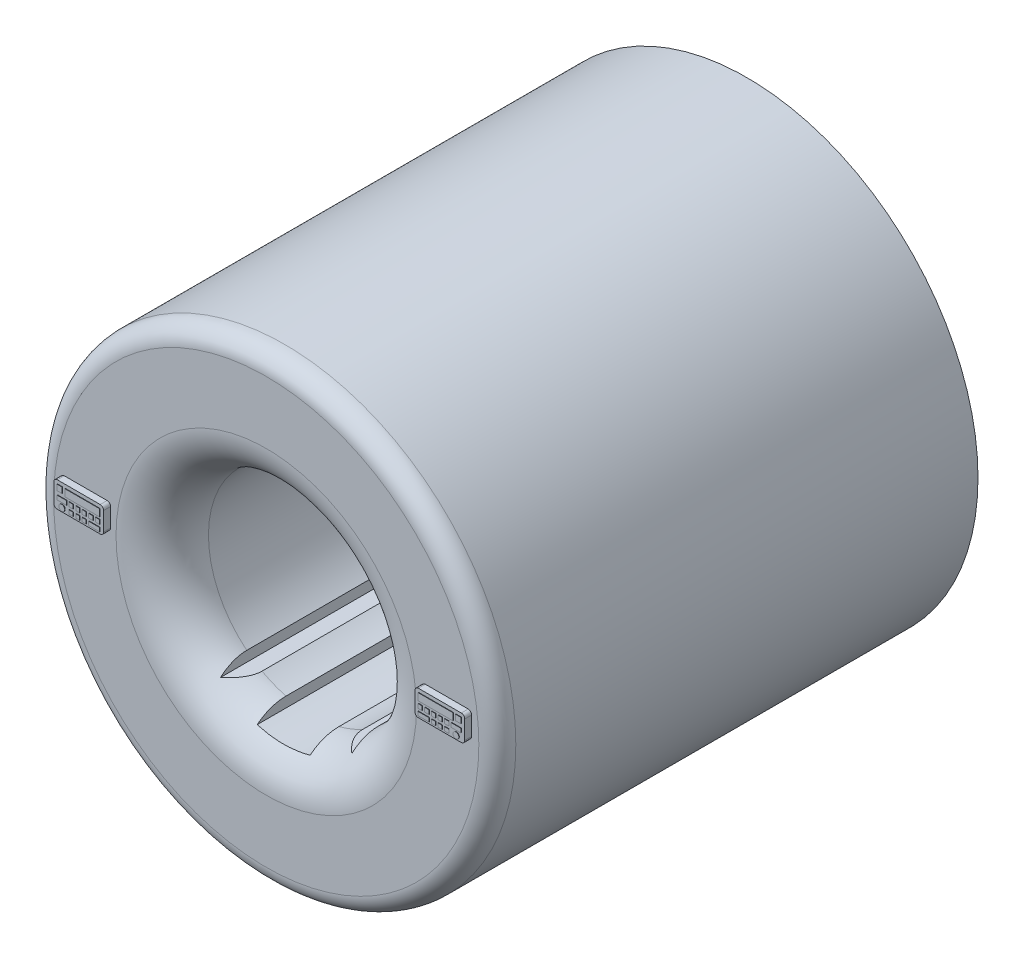
from build123d import *

# Parameters (mm, degrees)
SKETCH1_R           = 100
SKETCH1_R_2         = 45
BOSS_EXTRUDE1_DEPTH = 200
FILLET1_R           = 8
FILLET2_R           = 20
CUT_EXTRUDE1_DEPTH  = 200
SKETCH3_W           = 21.544123994
SKETCH3_H           = 11.057339859
BOSS_EXTRUDE2_DEPTH = 3
FILLET3_R           = 1.5
SKETCH4_R           = 1.289060933
SKETCH4_W           = 15.13149362
SKETCH4_H           = 3.065252971
SKETCH4_W_2         = 2.299952362
SKETCH4_H_2         = 2.429436964
SKETCH4_W_3         = 1.819095979
SKETCH4_H_3         = 1.788232519
SKETCH4_W_4         = 1.827971019
SKETCH4_W_5         = 1.693323788
SKETCH4_W_6         = 1.708755518
SKETCH4_W_7         = 1.86770952
SKETCH4_W_8         = 4.247138883
SKETCH4_W_9         = 4.75974501
SKETCH4_H_4         = 1.629278517
BOSS_EXTRUDE3_DEPTH = 0.2
SKETCH5_R           = 100
BOSS_EXTRUDE4_DEPTH = 8
SCALE1_SCALE        = 15.6
SCALE2_SCALE        = 0.5


with BuildPart() as part:
    # Sketch1 → Boss-Extrude1 (new body)
    with BuildSketch(Plane.XY):
        Circle(SKETCH1_R)
        Circle(SKETCH1_R_2, mode=Mode.SUBTRACT)
    extrude(amount=BOSS_EXTRUDE1_DEPTH)

    # Fillet1
    fillet1_edges = [part.edges().sort_by_distance(p)[0] for p in [
        (-100, 0, 200),
    ]]
    fillet(fillet1_edges, radius=FILLET1_R)

    # Fillet2
    fillet2_edges = [part.edges().sort_by_distance(p)[0] for p in [
        (-45, 0, 200),
    ]]
    fillet(fillet2_edges, radius=FILLET2_R)

    # Sketch2 → Cut-Extrude1 (cut)
    with BuildSketch(Plane(origin=(0, 0, 0), x_dir=(-1, 0, 0), z_dir=(0, 0, -1))):
        with BuildLine():
            Line((-28.43159427, -34.880430721), (28.43159427, -34.880430721))
            Line((28.43159427, -34.880430721), (28.43159427, -39.361060603))
            Line((28.43159427, -39.361060603), (11.44568617, -39.361060603))
            Line((11.44568617, -39.361060603), (11.44568617, -48.0006973))
            ThreePointArc((11.44568617, -48.0006973), (0, -49.480629882), (-11.44568617, -48.0006973))
            Line((-11.44568617, -48.0006973), (-11.44568617, -39.361060603))
            Line((-11.44568617, -39.361060603), (-28.43159427, -39.361060603))
            Line((-28.43159427, -39.361060603), (-28.43159427, -34.880430721))
        make_face()
    extrude(amount=-CUT_EXTRUDE1_DEPTH, mode=Mode.SUBTRACT)

    # Sketch3 → Boss-Extrude2 (add)
    with BuildSketch(Plane.XY.offset(200)):
        with Locations((78.121999913, 5.52866993)):
            Rectangle(SKETCH3_W, SKETCH3_H)
        with Locations((-78.121999913, 5.52866993)):
            Rectangle(SKETCH3_W, SKETCH3_H)
    extrude(amount=BOSS_EXTRUDE2_DEPTH)

    # Fillet3
    fillet3_edges = [part.edges().sort_by_distance(p)[0] for p in [
        (67.349937916, 11.057339859, 201.5),
        (67.349937916, 0, 201.5),
        (88.89406191, 0, 201.5),
        (88.89406191, 11.057339859, 201.5),
        (-88.89406191, 0, 201.5),
        (-67.349937916, 0, 201.5),
        (-67.349937916, 11.057339859, 201.5),
        (-88.89406191, 11.057339859, 201.5),
    ]]
    fillet(fillet3_edges, radius=FILLET3_R)

    # Sketch4 → Boss-Extrude3 (add)
    with BuildSketch(Plane.XY.offset(203)):
        with Locations((85.270492468, 1.703597588)):
            Circle(SKETCH4_R)
        with Locations((-85.270492468, 1.703597588)):
            Circle(SKETCH4_R)
        with Locations((76.415684726, 8.024713374)):
            Rectangle(SKETCH4_W, SKETCH4_H)
        with Locations((86.244085729, 8.342621377)):
            Rectangle(SKETCH4_W_2, SKETCH4_H_2)
        with Locations((69.759485906, 4.564769617)):
            Rectangle(SKETCH4_W_3, SKETCH4_H_3)
        with Locations((72.695697416, 4.564769617)):
            Rectangle(SKETCH4_W_4, SKETCH4_H_3)
        with Locations((75.569022832, 4.564769617)):
            Rectangle(SKETCH4_W_5, SKETCH4_H_3)
        with Locations((78.358433726, 4.564769617)):
            Rectangle(SKETCH4_W_6, SKETCH4_H_3)
        with Locations((81.259344257, 4.564769617)):
            Rectangle(SKETCH4_W_7, SKETCH4_H_3)
        with Locations((85.270492469, 4.564769617)):
            Rectangle(SKETCH4_W_8, SKETCH4_H_3)
        with Locations((71.229810421, 1.703597588)):
            Rectangle(SKETCH4_W_9, SKETCH4_H_4)
        with Locations((75.569022832, 1.703597588)):
            Rectangle(SKETCH4_W_5, SKETCH4_H_4)
        with Locations((78.358433726, 1.703597588)):
            Rectangle(SKETCH4_W_6, SKETCH4_H_4)
        with Locations((81.259344257, 1.703597588)):
            Rectangle(SKETCH4_W_7, SKETCH4_H_4)
        with Locations((-81.259344257, 1.703597588)):
            Rectangle(SKETCH4_W_7, SKETCH4_H_4)
        with Locations((-78.358433726, 1.703597588)):
            Rectangle(SKETCH4_W_6, SKETCH4_H_4)
        with Locations((-75.569022832, 1.703597588)):
            Rectangle(SKETCH4_W_5, SKETCH4_H_4)
        with Locations((-71.229810421, 1.703597588)):
            Rectangle(SKETCH4_W_9, SKETCH4_H_4)
        with Locations((-85.270492469, 4.564769617)):
            Rectangle(SKETCH4_W_8, SKETCH4_H_3)
        with Locations((-81.259344257, 4.564769617)):
            Rectangle(SKETCH4_W_7, SKETCH4_H_3)
        with Locations((-78.358433726, 4.564769617)):
            Rectangle(SKETCH4_W_6, SKETCH4_H_3)
        with Locations((-75.569022832, 4.564769617)):
            Rectangle(SKETCH4_W_5, SKETCH4_H_3)
        with Locations((-72.695697416, 4.564769617)):
            Rectangle(SKETCH4_W_4, SKETCH4_H_3)
        with Locations((-69.759485906, 4.564769617)):
            Rectangle(SKETCH4_W_3, SKETCH4_H_3)
        with Locations((-86.244085729, 8.342621377)):
            Rectangle(SKETCH4_W_2, SKETCH4_H_2)
        with Locations((-76.415684726, 8.024713374)):
            Rectangle(SKETCH4_W, SKETCH4_H)
    extrude(amount=BOSS_EXTRUDE3_DEPTH)

    # Sketch5 → Boss-Extrude4 (add)
    with BuildSketch(Plane(origin=(0, 0, 0), x_dir=(-1, 0, 0), z_dir=(0, 0, -1))):
        Circle(SKETCH5_R)
        with BuildLine():
            Line((-28.43159427, -39.361060603), (-28.43159427, -34.880430721))
            ThreePointArc((-28.43159427, -34.880430721), (0, 45), (28.43159427, -34.880430721))
            Line((28.43159427, -34.880430721), (28.43159427, -39.361060603))
            Line((28.43159427, -39.361060603), (21.810706275, -39.361060603))
            ThreePointArc((21.810706275, -39.361060603), (16.757721923, -41.763366195), (11.44568617, -43.520067418))
            Line((11.44568617, -43.520067418), (11.44568617, -45.760382359))
            Line((11.44568617, -45.760382359), (11.44568617, -48.0006973))
            ThreePointArc((11.44568617, -48.0006973), (0, -49.480629882), (-11.44568617, -48.0006973))
            Line((-11.44568617, -48.0006973), (-11.44568617, -43.520067418))
            ThreePointArc((-11.44568617, -43.520067418), (-16.757721923, -41.763366195), (-21.810706275, -39.361060603))
            Line((-21.810706275, -39.361060603), (-28.43159427, -39.361060603))
        make_face(mode=Mode.SUBTRACT)
    extrude(amount=BOSS_EXTRUDE4_DEPTH)


with BuildPart() as part_1:
    # Scale1: scaled about (-1e-09, 0.224288637, 95.374877124)
    add(part.part.scale(SCALE1_SCALE).moved(Location((1.5e-08, -3.2746141, -1392.47320601))))


with BuildPart() as part_2:
    # Scale2: scaled about (-5e-09, 0.224288632, 95.374877131)
    add(part_1.part.scale(SCALE2_SCALE).moved(Location((-3e-09, 0.112144316, 47.687438566))))


solid = part_2.part
